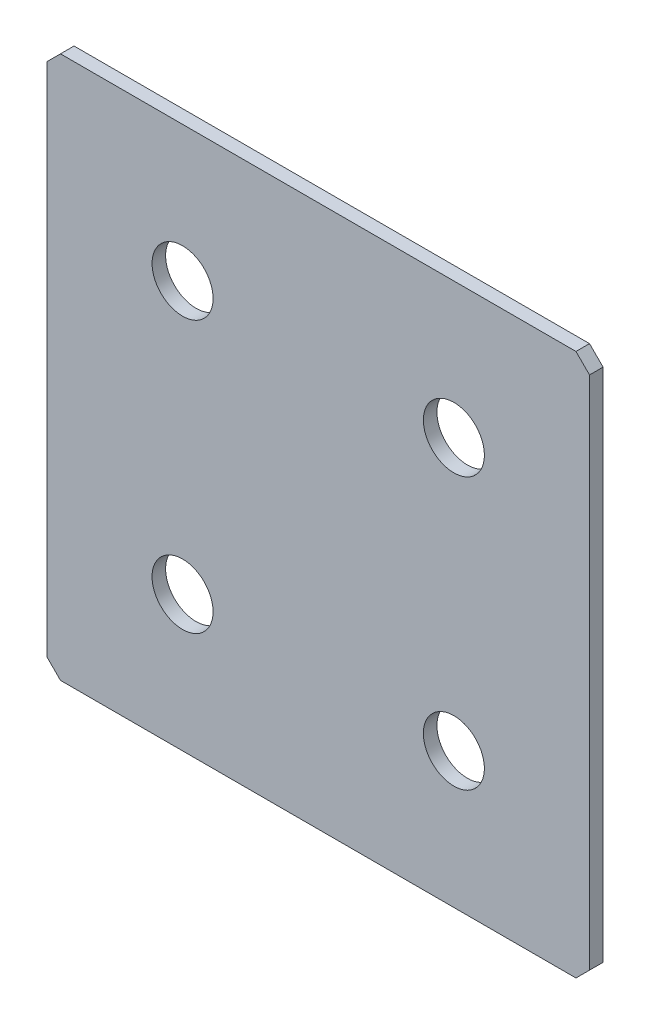
from build123d import *

# Parameters (mm, degrees)
SKETCH_1_W        = 80
SKETCH_1_H        = 80
EXTRUDE_1_DEPTH   = 2
CHAMFER_1_SIZE    = 2
HOLE_WIZARD_M81_D = 9


with BuildPart() as part:
    # Эскиз1 → Бобышка-Вытянуть1 (new body)
    with BuildSketch(Plane.XY):
        Rectangle(SKETCH_1_W, SKETCH_1_H)
    extrude(amount=EXTRUDE_1_DEPTH)

    # Фаска1
    chamfer_1_edges = [part.edges().sort_by_distance(p)[0] for p in [
        (40, -40, 1),
        (-40, -40, 1),
        (-40, 40, 1),
        (40, 40, 1),
    ]]
    chamfer(chamfer_1_edges, length=CHAMFER_1_SIZE)

    # Отверстие с зазором M81 (through all)
    with Locations(Plane.XY.offset(2)):
        with Locations((-20, 20), (20, 20), (-20, -20), (20, -20)):
            Hole(HOLE_WIZARD_M81_D / 2)


solid = part.part
